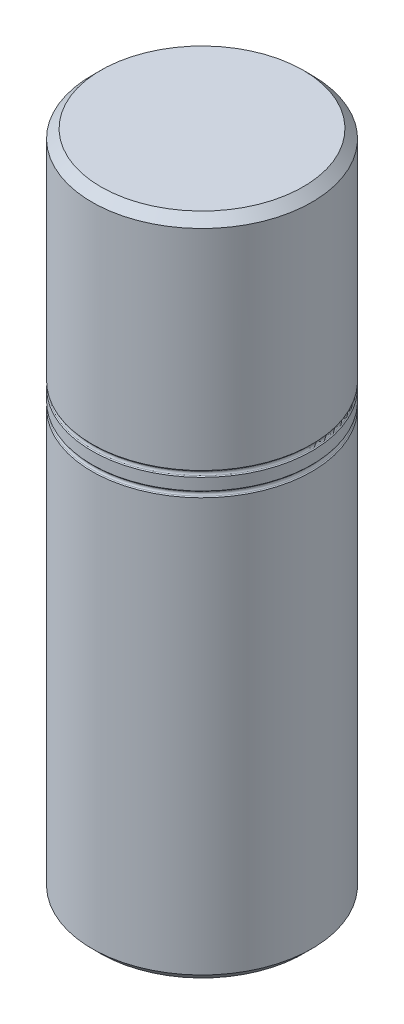
from build123d import *

# Parameters (mm, degrees)
LPATTERN1_COUNT = 2
LPATTERN1_PITCH = 1.524


with BuildPart() as part:
    # Sketch1 → Revolve1 (revolve)
    with BuildSketch(Plane.XY, mode=Mode.PRIVATE) as revolve1_sk:
        Polygon((9.4615, 0.762), (9.4615, 56.388), (8.6995, 57.15), (0, 57.15), (0, 2.286), (4.5466, 2.286), (4.8006, 2.032), (4.8006, 0), (8.6995, 0), align=None)
    revolve(revolve1_sk.sketch.rotate(Axis((0, 0, 0), (0, 1, 0)), 90), axis=Axis((0, 0, 0), (0, 1, 0)))  # turned: the seam where the file's is

    # Sketch2 → Cut-Revolve1 (revolve, cut)
    with BuildSketch(Plane.XY, mode=Mode.PRIVATE) as cut_revolve1_sk:
        with BuildLine():
            Line((9.525, 36.2585), (9.525, 36.8935))
            Line((9.525, 36.8935), (9.387105122, 36.755605122))
            ThreePointArc((9.387105122, 36.755605122), (9.312710245, 36.576), (9.387105122, 36.396394878))
            Line((9.387105122, 36.396394878), (9.525, 36.2585))
        make_face()
    cut_revolve1 = revolve(cut_revolve1_sk.sketch.rotate(Axis((0, 0, 0), (0, 1, 0)), 90), axis=Axis((0, 0, 0), (0, 1, 0)), mode=Mode.SUBTRACT)  # turned: the seam where the file's is

    # LPattern1: Cut-Revolve1 ×2
    with Locations(*[(0, i * LPATTERN1_PITCH, 0) for i in range(1, LPATTERN1_COUNT)]):
        add(cut_revolve1, mode=Mode.SUBTRACT)


solid = part.part
